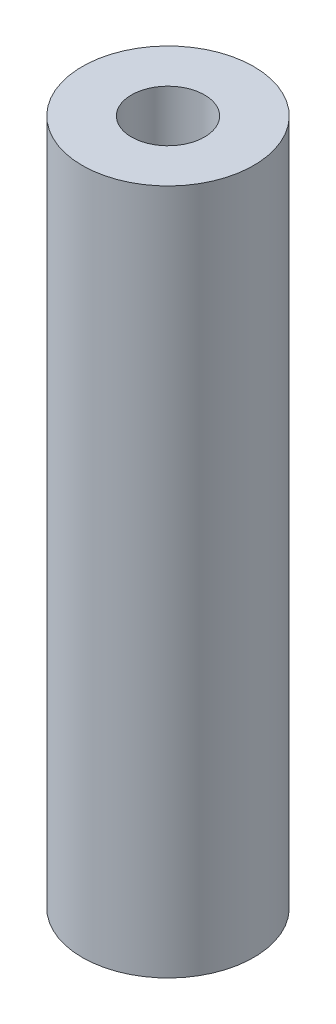
from build123d import *

# Parameters (mm, degrees)
SKETCH1_R                 = 3.175
BOSS_EXTRUDE1_DEPTH       = 25.4
TAP_DRILL_FOR_6_32_TAP1_D = 2.7051


with BuildPart() as part:
    # Sketch1 → Boss-Extrude1 (new body)
    with BuildSketch(Plane(origin=(0, 0, 0), x_dir=(1, 0, 0), z_dir=(0, 1, 0))):
        Circle(SKETCH1_R)
    extrude(amount=BOSS_EXTRUDE1_DEPTH)

    # Tap Drill for #6-32 Tap1 (through all)
    with Locations(Plane(origin=(0, 25.4, 0), x_dir=(1, 0, 0), z_dir=(0, 1, 0))):
        with Locations((0, 0)):
            Hole(TAP_DRILL_FOR_6_32_TAP1_D / 2)


solid = part.part
